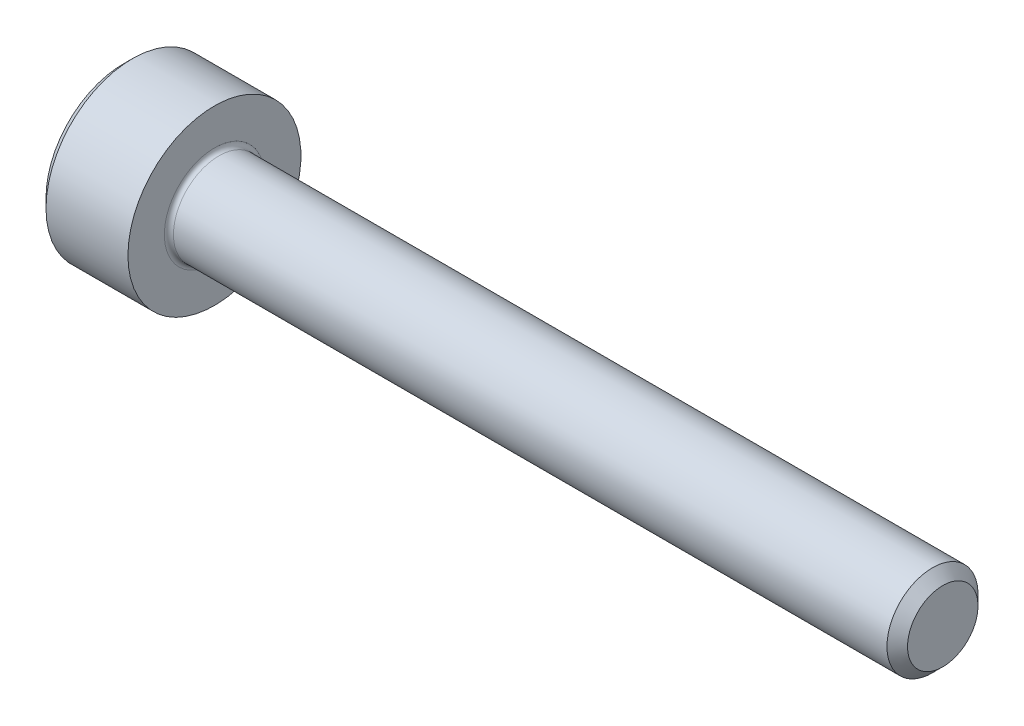
from build123d import *

# Parameters (mm, degrees)
FILLET1_R   = 0.1
HEX_2_DEPTH = 1


with BuildPart() as part:
    # BodySke → Base-Revolve (revolve)
    with BuildSketch(Plane.XY):
        Polygon((0, 0), (0, 1.7), (0.2, 1.9), (2, 1.9), (2, 1), (17.774, 1), (18, 0.774), (18, 0), align=None)
    revolve(axis=Axis((-31.75, 0, 0), (1, 0, 0)))

    # Fillet1
    fillet1_edges = [part.edges().sort_by_distance(p)[0] for p in [
        (2, -1, 0),
    ]]
    fillet(fillet1_edges, radius=FILLET1_R)

    # Sketch2 → Hex-PreBroach (revolve, cut)
    with BuildSketch(Plane.XY):
        Polygon((0, 0.7725), (1, 0.7725), (1.446003083, 0), (0, 0), align=None)
    revolve(axis=Axis((0, 0, 0), (1, 0, 0)), mode=Mode.SUBTRACT)

    # Sketch3 → Hex 2 (cut)
    with BuildSketch(Plane(origin=(0, 0, 0), x_dir=(0, 0.5, 0.866025404), z_dir=(-1, 0, 0))):
        Polygon((0.446003083, 0.7725), (-0.446003083, 0.7725), (-0.892006166, 0), (-0.446003083, -0.7725), (0.446003083, -0.7725), (0.892006166, 0), align=None)
    extrude(amount=-HEX_2_DEPTH, mode=Mode.SUBTRACT)


solid = part.part
